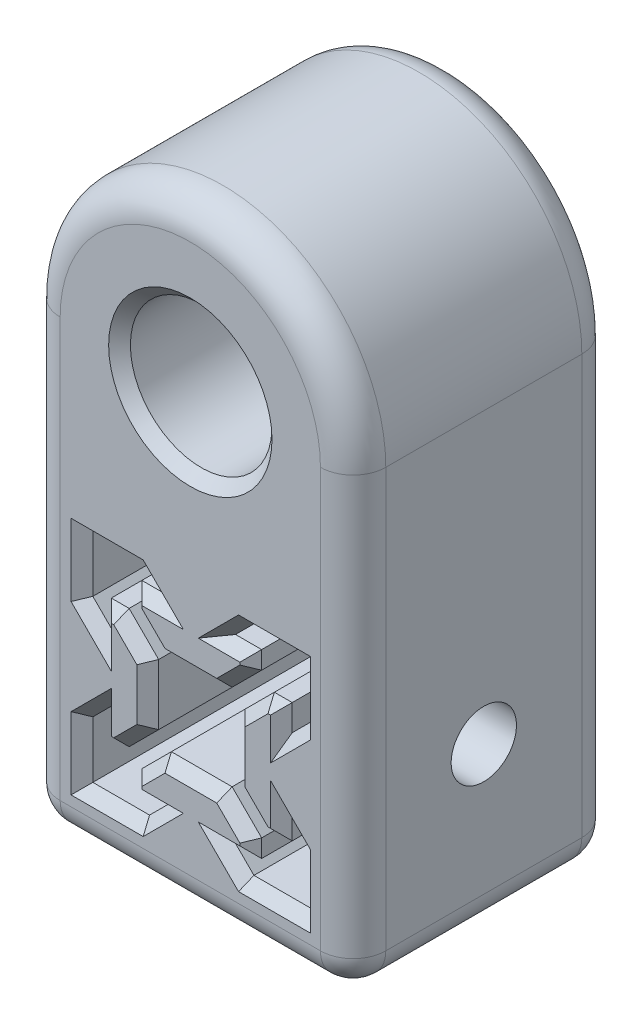
from build123d import *

# Parameters (mm, degrees)
BOSS_EXTRUDE1_DEPTH = 24
SKETCH4_R           = 6.5
BOSS_EXTRUDE2_DEPTH = 24
SKETCH3_R           = 3
CUT_EXTRUDE1_DEPTH  = 30.899298428
FILLET1_R           = 3
CHAMFER1_SIZE       = 1


with BuildPart() as part:
    # Sketch1 → Boss-Extrude1 (new body)
    with BuildSketch(Plane.XY):
        Polygon((0, 15), (14.899298428, 15), (14.899298428, -14.949649214), (-15, -14.949649214), (-15, 15), align=None)
        Polygon((-10, 10), (-4.792538857, 10), (-3.1, 8.307461143), (-5.5, 8.307461143), (-5.5, 6.667461143), (-2.79, 3.957461143), (2.79, 3.957461143), (5.5, 6.667461143), (5.5, 8.307461143), (3.1, 8.307461143), (4.792538857, 10), (10, 10), (10, 4.792538857), (8.307461143, 3.1), (8.307461143, 5.5), (6.667461143, 5.5), (3.957461143, 2.79), (3.957461143, -2.79), (6.667461143, -5.5), (8.307461143, -5.5), (8.307461143, -3.1), (10, -4.792538857), (10, -10), (4.792538857, -10), (3.1, -8.307461143), (5.5, -8.307461143), (5.5, -6.667461143), (2.79, -3.957461143), (-2.79, -3.957461143), (-5.5, -6.667461143), (-5.5, -8.307461143), (-3.1, -8.307461143), (-4.792538857, -10), (-10, -10), (-10, -4.792538857), (-8.307461143, -3.1), (-8.307461143, -5.5), (-6.667461143, -5.5), (-3.957461143, -2.79), (-3.957461143, 2.79), (-6.667461143, 5.5), (-8.307461143, 5.5), (-8.307461143, 3.1), (-10, 4.792538857), align=None, mode=Mode.SUBTRACT)
    extrude(amount=BOSS_EXTRUDE1_DEPTH)

    # Sketch4 → Boss-Extrude2 (add)
    with BuildSketch(Plane(origin=(0, 0, 0), x_dir=(-1, 0, 0), z_dir=(0, 0, -1))):
        with BuildLine():
            ThreePointArc((-14.899298428, 26.5), (0.050350786, 41.449649214), (15, 26.5))
            Line((15, 26.5), (15, 15))
            Line((15, 15), (-14.899298428, 15))
            Line((-14.899298428, 15), (-14.899298428, 26.5))
        make_face()
        with Locations((0.050350786, 26.5)):
            Circle(SKETCH4_R, mode=Mode.SUBTRACT)
    extrude(amount=-BOSS_EXTRUDE2_DEPTH)

    # Sketch3 → Cut-Extrude1 (cut, through all)
    with BuildSketch(Plane.ZY.offset(15)):
        with Locations((12, 0)):
            Circle(SKETCH3_R)
    extrude(amount=-CUT_EXTRUDE1_DEPTH, mode=Mode.SUBTRACT)

    # Fillet1
    fillet1_edges = [part.edges().sort_by_distance(p)[0] for p in [
        (-0.050350786, -14.949649214, 24),
        (14.899298428, 5.775175393, 24),
        (-0.050350786, 41.449649214, 24),
        (-0.050350786, 41.449649214, 0),
        (14.899298428, 5.775175393, 0),
        (-0.050350786, -14.949649214, 0),
        (-15, 5.775175393, 0),
        (-15, 5.775175393, 24),
        (14.899298428, -14.949649214, 12),
        (-15, -14.949649214, 12),
    ]]
    fillet(fillet1_edges, radius=FILLET1_R)

    # Chamfer1
    chamfer1_edges = [part.edges().sort_by_distance(p)[0] for p in [
        (6.449649214, 26.5, 24),
        (6.449649214, 26.5, 0),
        (-4.3, 8.307461143, 0),
        (-3.946269429, 9.153730571, 0),
        (-7.396269429, 10, 0),
        (-10, 7.396269429, 0),
        (-9.153730571, 3.946269429, 0),
        (-8.307461143, 4.3, 0),
        (-7.487461143, 5.5, 0),
        (-5.312461143, 4.145, 0),
        (-3.957461143, 0, 0),
        (-5.312461143, -4.145, 0),
        (-7.487461143, -5.5, 0),
        (-8.307461143, -4.3, 0),
        (-9.153730571, -3.946269429, 0),
        (-10, -7.396269429, 0),
        (-7.396269429, -10, 0),
        (-3.946269429, -9.153730571, 0),
        (-4.3, -8.307461143, 0),
        (-5.5, -7.487461143, 0),
        (-4.145, -5.312461143, 0),
        (0, -3.957461143, 0),
        (4.145, -5.312461143, 0),
        (5.5, -7.487461143, 0),
        (4.3, -8.307461143, 0),
        (3.946269429, -9.153730571, 0),
        (7.396269429, -10, 0),
        (10, -7.396269429, 0),
        (9.153730571, -3.946269429, 0),
        (8.307461143, -4.3, 0),
        (7.487461143, -5.5, 0),
        (5.312461143, -4.145, 0),
        (3.957461143, 0, 0),
        (5.312461143, 4.145, 0),
        (7.487461143, 5.5, 0),
        (8.307461143, 4.3, 0),
        (9.153730571, 3.946269429, 0),
        (10, 7.396269429, 0),
        (7.396269429, 10, 0),
        (3.946269429, 9.153730571, 0),
        (4.3, 8.307461143, 0),
        (5.5, 7.487461143, 0),
        (4.145, 5.312461143, 0),
        (0, 3.957461143, 0),
        (-4.145, 5.312461143, 0),
        (-5.5, 7.487461143, 0),
        (-4.3, 8.307461143, 24),
        (-3.946269429, 9.153730571, 24),
        (-7.396269429, 10, 24),
        (-10, 7.396269429, 24),
        (-9.153730571, 3.946269429, 24),
        (-8.307461143, 4.3, 24),
        (-7.487461143, 5.5, 24),
        (-5.312461143, 4.145, 24),
        (-3.957461143, 0, 24),
        (-5.312461143, -4.145, 24),
        (-7.487461143, -5.5, 24),
        (-8.307461143, -4.3, 24),
        (-9.153730571, -3.946269429, 24),
        (-10, -7.396269429, 24),
        (-7.396269429, -10, 24),
        (-3.946269429, -9.153730571, 24),
        (-4.3, -8.307461143, 24),
        (-5.5, -7.487461143, 24),
        (-4.145, -5.312461143, 24),
        (0, -3.957461143, 24),
        (4.145, -5.312461143, 24),
        (5.5, -7.487461143, 24),
        (4.3, -8.307461143, 24),
        (3.946269429, -9.153730571, 24),
        (7.396269429, -10, 24),
        (10, -7.396269429, 24),
        (9.153730571, -3.946269429, 24),
        (8.307461143, -4.3, 24),
        (7.487461143, -5.5, 24),
        (5.312461143, -4.145, 24),
        (3.957461143, 0, 24),
        (5.312461143, 4.145, 24),
        (7.487461143, 5.5, 24),
        (8.307461143, 4.3, 24),
        (9.153730571, 3.946269429, 24),
        (10, 7.396269429, 24),
        (7.396269429, 10, 24),
        (3.946269429, 9.153730571, 24),
        (4.3, 8.307461143, 24),
        (5.5, 7.487461143, 24),
        (4.145, 5.312461143, 24),
        (0, 3.957461143, 24),
        (-4.145, 5.312461143, 24),
        (-5.5, 7.487461143, 24),
    ]]
    chamfer(chamfer1_edges, length=CHAMFER1_SIZE)


solid = part.part
